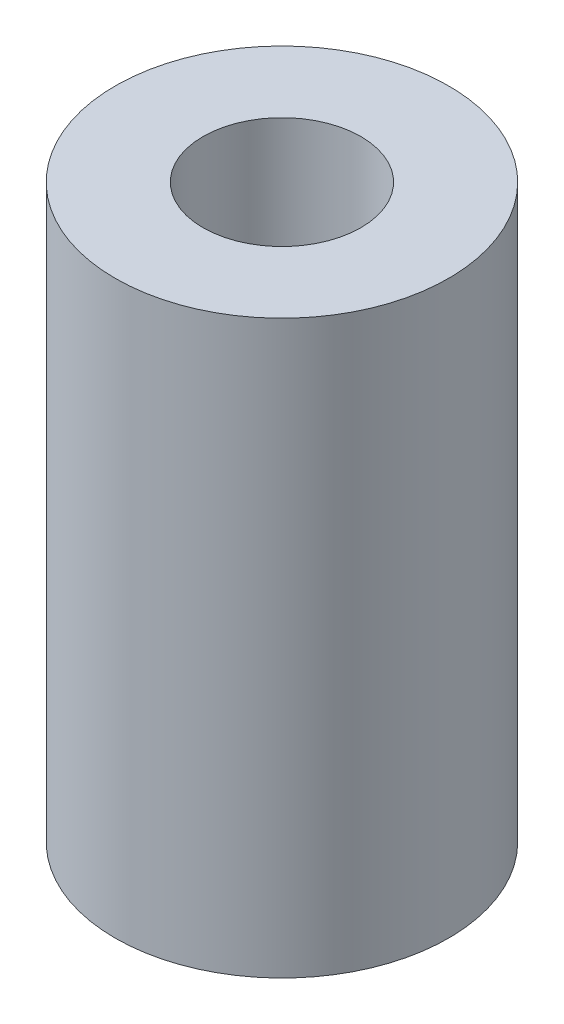
from build123d import *

# Parameters (mm, degrees)
SKETCH1_R           = 3.8
SKETCH1_R_2         = 1.8
BOSS_EXTRUDE1_DEPTH = 13.025


with BuildPart() as part:
    # Sketch1 → Boss-Extrude1 (new body)
    with BuildSketch(Plane(origin=(0, 0, 0), x_dir=(1, 0, 0), z_dir=(0, 1, 0))):
        Circle(SKETCH1_R)
        Circle(SKETCH1_R_2, mode=Mode.SUBTRACT)
    extrude(amount=BOSS_EXTRUDE1_DEPTH)


solid = part.part
